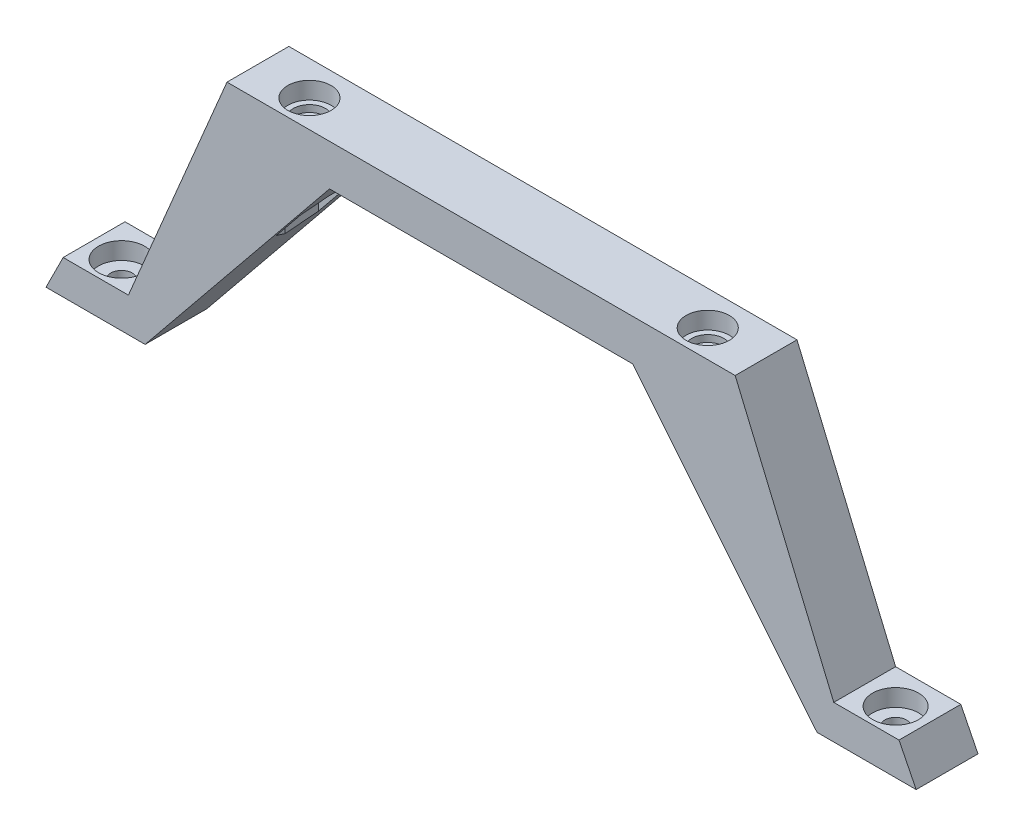
from build123d import *

# Parameters (mm, degrees)
EXTRUDE_1_DEPTH      = 10
SKETCH_7_R           = 1.55
CUT_EXTRUDE_1_DEPTH  = 36.544157215
CUT_EXTRUDE_2_DEPTH  = 8.5
SKETCH_14_R          = 1.575
CUT_EXTRUDE_10_DEPTH = 10
SKETCH_15_R          = 3.35
CUT_EXTRUDE_11_DEPTH = 2.5
SKETCH_19_W          = 126.714157214
SKETCH_19_H          = 0.99604336
CUT_EXTRUDE_14_DEPTH = 40.044157215


with BuildPart() as part:
    # 草图1 → 凸台-拉伸1 (new body)
    with BuildSketch(Plane.XY):
        Polygon((-3.188712924, 13.052848472), (33.811287076, 13.052848472), (33.811287076, 7.052848472), (15.60198174, 7.052848472), (11.74198174, 7.052848472), (-15.114428715, -25.991308743), (-17.614428715, -25.991308743), (-29.545791531, -25.991308743), (-27.045791531, -20.991308743), (-17.548712924, -20.991308743), align=None)
    extrude_1 = extrude(amount=EXTRUDE_1_DEPTH)

    # 镜向1: 凸台-拉伸1 across plane
    add(extrude_1.mirror(Plane(origin=(33.811287076, 13.052848472, 10), x_dir=(0, 0, 1), z_dir=(-1, 0, 0))))

    # 草图5 → 切除-旋转7 (revolve, cut)
    with BuildSketch(Plane.XY.offset(5)):
        Polygon((7.961287076, 13.052848472), (7.961287076, 10.552848472), (7.161287076, 10.552848472), (7.161287076, 9.552848472), (6.361287076, 9.552848472), (4.811287076, 9.552848472), (4.811287076, 13.052848472), align=None)
    cut_revolve_7 = revolve(axis=Axis((4.811287076, 9.552848472, 5), (0, 1, 0)), mode=Mode.SUBTRACT)

    # 草图7 → 切除-拉伸1 (cut, through all)
    with BuildSketch(Plane(origin=(0, 9.552848472, 0), x_dir=(1, 0, 0), z_dir=(0, 1, 0))):
        with Locations((4.811287076, -5)):
            Circle(SKETCH_7_R)
    cut_extrude_1 = extrude(amount=-CUT_EXTRUDE_1_DEPTH, mode=Mode.SUBTRACT)

    # 草图8 → 切除-拉伸2 (cut)
    with BuildSketch(Plane(origin=(0, -5.947151528, 0), x_dir=(1, 0, 0), z_dir=(0, 1, 0))):
        Polygon((8.333123718, -5), (6.572205397, -1.95), (3.050368755, -1.95), (1.289450434, -5), (3.050368755, -8.05), (6.572205397, -8.05), align=None)
    cut_extrude_2 = extrude(amount=CUT_EXTRUDE_2_DEPTH, mode=Mode.SUBTRACT)

    # 草图14 → 切除-拉伸10 (cut)
    with BuildSketch(Plane(origin=(0, -20.991308743, 0), x_dir=(1, 0, 0), z_dir=(0, 1, 0))):
        with Locations((-22.548712924, -5)):
            Circle(SKETCH_14_R)
    cut_extrude_10 = extrude(amount=-CUT_EXTRUDE_10_DEPTH, mode=Mode.SUBTRACT)

    # 草图15 → 切除-拉伸11 (cut)
    with BuildSketch(Plane(origin=(0, -20.991308743, 0), x_dir=(1, 0, 0), z_dir=(0, 1, 0))):
        with Locations((-22.548712924, -5)):
            Circle(SKETCH_15_R)
    cut_extrude_11 = extrude(amount=-CUT_EXTRUDE_11_DEPTH, mode=Mode.SUBTRACT)

    # 镜向3: 切除-旋转7, 切除-拉伸1, 切除-拉伸2, 切除-拉伸10, 切除-拉伸11 across plane
    add(cut_revolve_7.mirror(Plane(origin=(33.811287076, 0, 0), x_dir=(0, 0, 1), z_dir=(1, 0, 0))), mode=Mode.SUBTRACT)
    add(cut_extrude_1.mirror(Plane(origin=(33.811287076, 0, 0), x_dir=(0, 0, 1), z_dir=(1, 0, 0))), mode=Mode.SUBTRACT)
    add(cut_extrude_2.mirror(Plane(origin=(33.811287076, 0, 0), x_dir=(0, 0, 1), z_dir=(1, 0, 0))), mode=Mode.SUBTRACT)
    add(cut_extrude_10.mirror(Plane(origin=(33.811287076, 0, 0), x_dir=(0, 0, 1), z_dir=(1, 0, 0))), mode=Mode.SUBTRACT)
    add(cut_extrude_11.mirror(Plane(origin=(33.811287076, 0, 0), x_dir=(0, 0, 1), z_dir=(1, 0, 0))), mode=Mode.SUBTRACT)

    # 草图19 → 切除-拉伸14 (cut, through all)
    with BuildSketch(Plane(origin=(0, 13.052848472, 0), x_dir=(1, 0, 0), z_dir=(0, 1, 0))):
        with Locations((33.811287076, -9.50197832)):
            Rectangle(SKETCH_19_W, SKETCH_19_H)
    extrude(amount=-CUT_EXTRUDE_14_DEPTH, mode=Mode.SUBTRACT)


solid = part.part
